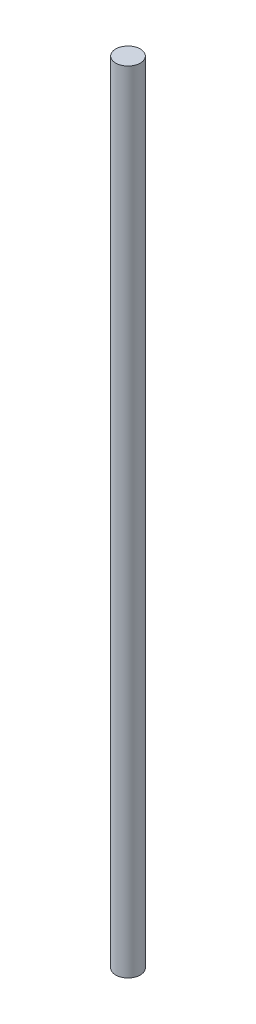
from build123d import *

# Parameters (mm, degrees)
SKETCH1_R           = 3
BOSS_EXTRUDE1_DEPTH = 193.04


with BuildPart() as part:
    # Sketch1 → Boss-Extrude1 (new body)
    with BuildSketch(Plane(origin=(0, 0, 0), x_dir=(1, 0, 0), z_dir=(0, 1, 0))):
        Circle(SKETCH1_R)
    extrude(amount=BOSS_EXTRUDE1_DEPTH)


solid = part.part
